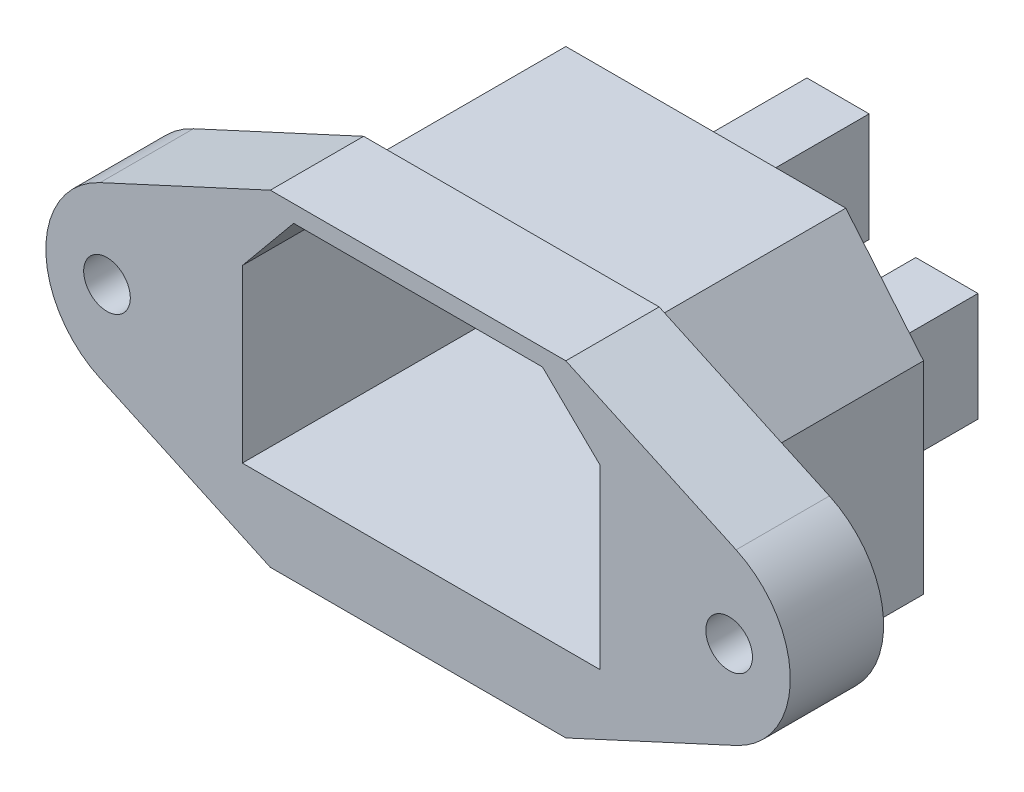
from build123d import *

# Parameters (mm, degrees)
RESSALTO_EXTRUS_O1_DEPTH = 12.5
ESBO_O2_W                = 4
ESBO_O2_H                = 7
RESSALTO_EXTRUS_O2_DEPTH = 8.5
RESSALTO_EXTRUS_O3_DEPTH = 6
ESBO_O4_R                = 1.5
CORTE_EXTRUS_O1_DEPTH    = 6
FILETE1_R                = 6
CORTE_EXTRUS_O2_DEPTH    = 16.5


with BuildPart() as part:
    # Esboço1 → Ressalto-extrusão1 (new body)
    with BuildSketch(Plane.XY):
        Polygon((-9, 12.5), (9, 12.5), (14, 6.5), (14, -6.5), (-14, -6.5), (-14, 6.5), align=None)
    extrude(amount=RESSALTO_EXTRUS_O1_DEPTH)

    # Esboço2 → Ressalto-extrusão2 (add)
    with BuildSketch(Plane(origin=(0, 0, 0), x_dir=(-1, 0, 0), z_dir=(0, 0, -1))):
        with Locations((-7, 0)):
            Rectangle(ESBO_O2_W, ESBO_O2_H)
        with Locations((0, 6.5)):
            Rectangle(ESBO_O2_W, ESBO_O2_H)
        with Locations((7, 0)):
            Rectangle(ESBO_O2_W, ESBO_O2_H)
    extrude(amount=RESSALTO_EXTRUS_O2_DEPTH)

    # Esboço3 → Ressalto-extrusão3 (add)
    with BuildSketch(Plane.XY.offset(12.5)):
        Polygon((-9.5, -7.5), (9.5, -7.5), (32.25, 3), (9.5, 13.5), (-9.5, 13.5), (-32.25, 3), align=None)
    extrude(amount=RESSALTO_EXTRUS_O3_DEPTH)

    # Esboço4 → Corte-extrusão1 (cut)
    with BuildSketch(Plane.XY.offset(18.5)):
        with Locations((-20, 3)):
            Circle(ESBO_O4_R)
        with Locations((20, 3)):
            Circle(ESBO_O4_R)
    extrude(amount=-CORTE_EXTRUS_O1_DEPTH, mode=Mode.SUBTRACT)

    # Filete1
    filete1_edges = [part.edges().sort_by_distance(p)[0] for p in [
        (-32.25, 3, 15.5),
        (32.25, 3, 15.5),
    ]]
    fillet(filete1_edges, radius=FILETE1_R)

    # Esboço5 → Corte-extrusão2 (cut)
    with BuildSketch(Plane.XY.offset(18.5)):
        Polygon((-8, 12.404340661), (8, 12.404340661), (11.700014981, 8.793750875), (11.700014981, -2.595659339), (-11.299985019, -2.595659339), (-11.299985019, 8.404340661), align=None)
    extrude(amount=-CORTE_EXTRUS_O2_DEPTH, mode=Mode.SUBTRACT)


solid = part.part
